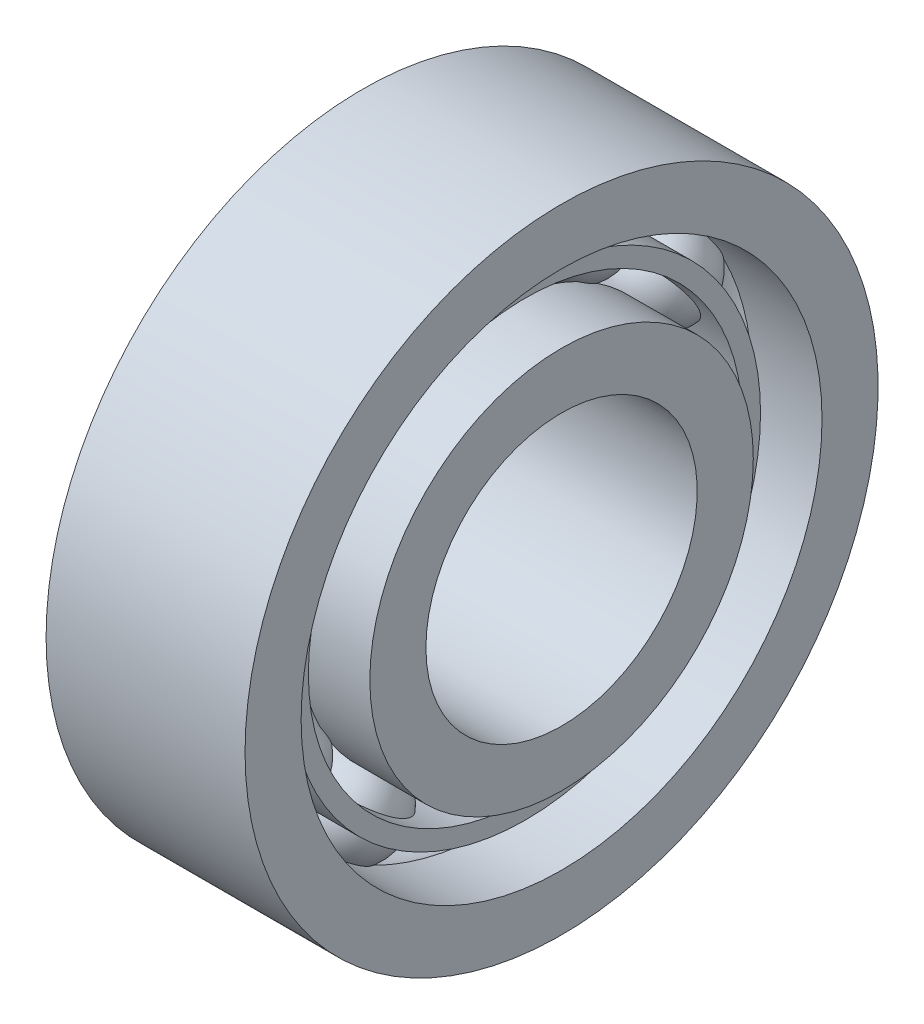
from build123d import *

# Parameters (mm, degrees)
R_P_TITION_CIRCULAIRE1_COUNT = 12
ESQUISSE4_W                  = 7
ESQUISSE4_H                  = 1


with BuildPart() as part:
    # Esquisse1 → Révolution1 (revolve)
    with BuildSketch(Plane.XY, mode=Mode.PRIVATE) as r_volution1_sk:
        with BuildLine():
            Line((-5.5, 7.5), (5.5, 7.5))
            Line((5.5, 7.5), (5.5, 10.6))
            Line((5.5, 10.6), (1.624807681, 10.6))
            ThreePointArc((1.624807681, 10.6), (0, 10), (-1.624807681, 10.6))
            Line((-1.624807681, 10.6), (-5.5, 10.6))
            Line((-5.5, 10.6), (-5.5, 7.5))
        make_face()
    revolve(r_volution1_sk.sketch.rotate(Axis((0, 0, 0), (1, 0, 0)), 90), axis=Axis((0, 0, 0), (1, 0, 0)))  # turned: the seam where the file's is

    # Esquisse2 → Révolution2 (revolve)
    with BuildSketch(Plane.XY):
        with BuildLine():
            Line((0, 15.1), (0, 9.9))
            ThreePointArc((0, 9.9), (2.6, 12.5), (0, 15.1))
        make_face()
    r_volution2 = revolve(axis=Axis((0, 15.1, 0), (0, -1, 0)))

    # Répétition circulaire1: Révolution2 ×12 about axis
    r_p_tition_circulaire1_axis = Axis((0, 0, 0), (1, 0, 0))
    for i in range(1, R_P_TITION_CIRCULAIRE1_COUNT):
        add(r_volution2.rotate(r_p_tition_circulaire1_axis, i * 360 / R_P_TITION_CIRCULAIRE1_COUNT))

    # Esquisse3 → Révolution3 (revolve)
    with BuildSketch(Plane.XY, mode=Mode.PRIVATE) as r_volution3_sk:
        with BuildLine():
            Line((1.624807681, 14.4), (5.5, 14.4))
            Line((5.5, 14.4), (5.5, 17.5))
            Line((5.5, 17.5), (-5.5, 17.5))
            Line((-5.5, 17.5), (-5.5, 14.4))
            Line((-5.5, 14.4), (-1.624807681, 14.4))
            ThreePointArc((-1.624807681, 14.4), (0, 15), (1.624807681, 14.4))
        make_face()
    revolve(r_volution3_sk.sketch.rotate(Axis((0, 0, 0), (1, 0, 0)), 90), axis=Axis((0, 0, 0), (1, 0, 0)))  # turned: the seam where the file's is

    # Esquisse4 → Révolution4 (revolve)
    with BuildSketch(Plane.XY, mode=Mode.PRIVATE) as r_volution4_sk:
        with Locations((0, 12.5)):
            Rectangle(ESQUISSE4_W, ESQUISSE4_H)
    revolve(r_volution4_sk.sketch.rotate(Axis((0, 0, 0), (1, 0, 0)), 90), axis=Axis((0, 0, 0), (1, 0, 0)))  # turned: the seam where the file's is


solid = part.part
